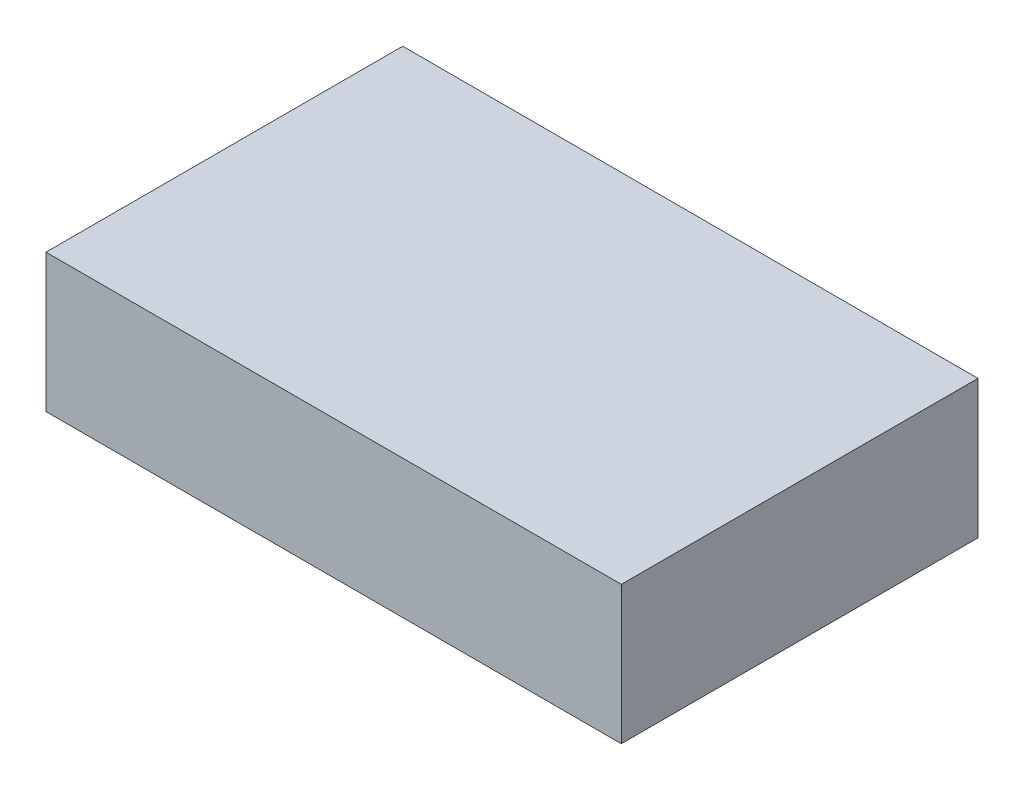
from build123d import *

# Parameters (mm, degrees)
SKETCH1_W           = 158.75
SKETCH1_H           = 98.425
BOSS_EXTRUDE1_DEPTH = 38.1


with BuildPart() as part:
    # Sketch1 → Boss-Extrude1 (new body)
    with BuildSketch(Plane(origin=(0, 0, 0), x_dir=(1, 0, 0), z_dir=(0, 1, 0))):
        Rectangle(SKETCH1_W, SKETCH1_H)
    extrude(amount=BOSS_EXTRUDE1_DEPTH)


solid = part.part
